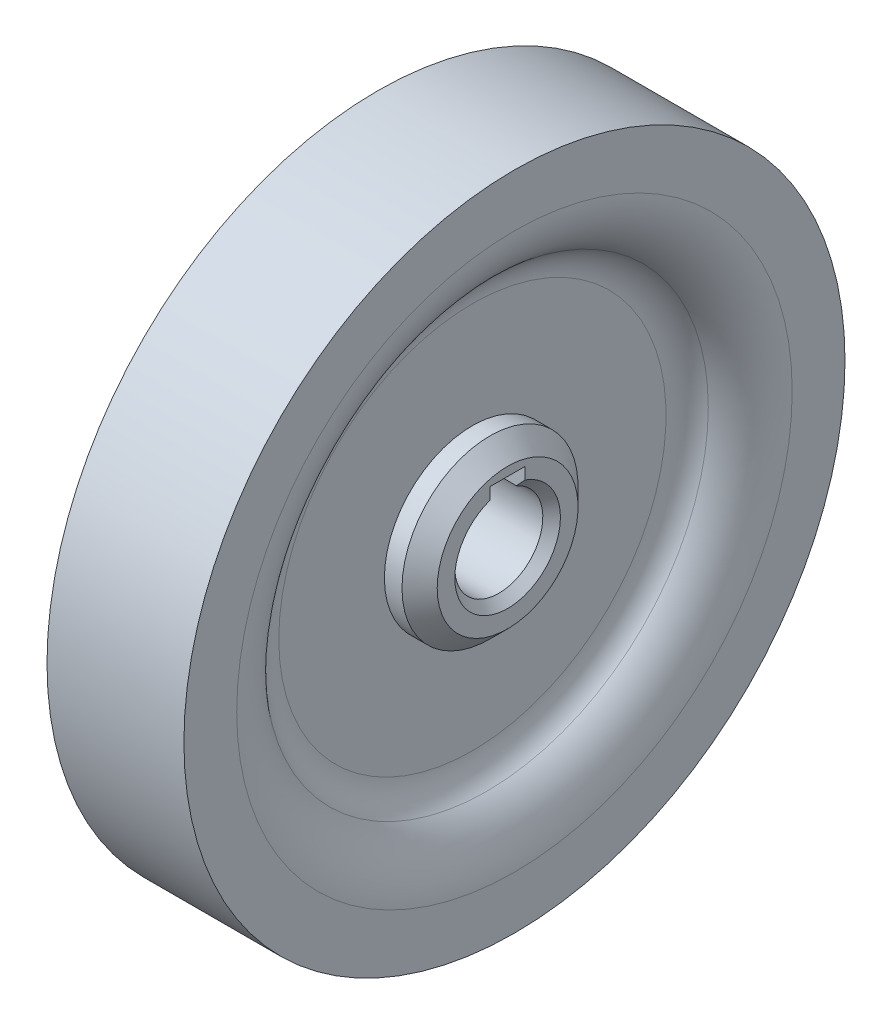
from build123d import *

# Parameters (mm, degrees)
SFAZOWANIE1_SIZE           = 2
SFAZOWANIE2_SIZE           = 2
OTW_R_10_0_10_1_D          = 10
SFAZOWANIE3_SIZE           = 1
SZKIC4_W                   = 4
SZKIC4_H                   = 4
WYTNIJ_WYCI_GNI_CIE1_DEPTH = 15.777533215


with BuildPart() as part:
    # Szkic1 → Obrót1 (revolve)
    with BuildSketch(Plane.XY, mode=Mode.PRIVATE) as obr_t1_sk:
        with BuildLine():
            Line((-7.777533215, 37.555066431), (-7.777533215, 31.555066431))
            ThreePointArc((-7.777533215, 31.555066431), (-6.938880447, 28.002476296), (-4.6, 25.2))
            ThreePointArc((-4.6, 25.2), (-3.422291236, 23.788854382), (-3, 22))
            Line((-3, 22), (-3, 10))
            Line((-3, 10), (-7, 10))
            Line((-7, 10), (-7, 0))
            Line((-7, 0), (7, 0))
            Line((7, 0), (7, 10))
            Line((7, 10), (3, 10))
            Line((3, 10), (3, 22))
            ThreePointArc((3, 22), (3.422291236, 23.788854382), (4.6, 25.2))
            ThreePointArc((4.6, 25.2), (6.938880447, 28.002476296), (7.777533215, 31.555066431))
            Line((7.777533215, 31.555066431), (7.777533215, 37.555066431))
            Line((7.777533215, 37.555066431), (-7.777533215, 37.555066431))
        make_face()
    revolve(obr_t1_sk.sketch.rotate(Axis((-1.77338341, 0, 0), (1, 0, 0)), 90), axis=Axis((-1.77338341, 0, 0), (1, 0, 0)))  # turned: the seam where the file's is

    # Sfazowanie1
    sfazowanie1_edges = [part.edges().sort_by_distance(p)[0] for p in [
        (7, 0, -10),
    ]]
    chamfer(sfazowanie1_edges, length=SFAZOWANIE1_SIZE)

    # Sfazowanie2
    sfazowanie2_edges = [part.edges().sort_by_distance(p)[0] for p in [
        (-7, 0, -10),
    ]]
    chamfer(sfazowanie2_edges, length=SFAZOWANIE2_SIZE)

    # Otwór Ø10.0 (10)1 (through all)
    with Locations(Plane.ZY.offset(7)):
        with Locations((0, 0)):
            Hole(OTW_R_10_0_10_1_D / 2)

    # Sfazowanie3
    sfazowanie3_edges = [part.edges().sort_by_distance(p)[0] for p in [
        (7, 0, 5),
        (-7, 0, 5),
    ]]
    chamfer(sfazowanie3_edges, length=SFAZOWANIE3_SIZE)

    # Szkic4 → Wytnij-wyciągnięcie1 (cut, through all)
    with BuildSketch(Plane(origin=(7, 0, 0), x_dir=(0, 0, -1), z_dir=(1, 0, 0))):
        with Locations((0, 5)):
            Rectangle(SZKIC4_W, SZKIC4_H)
    extrude(amount=-WYTNIJ_WYCI_GNI_CIE1_DEPTH, mode=Mode.SUBTRACT)


solid = part.part
